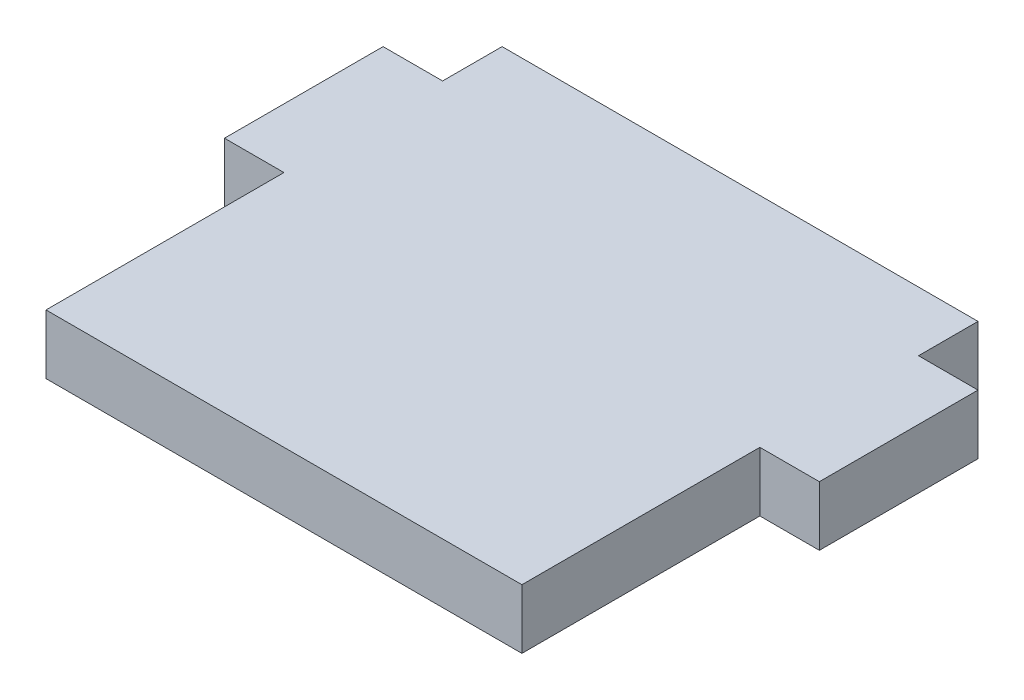
from build123d import *

# Parameters (mm, degrees)
BOSS_EXTRUDE1_DEPTH = 19.05


with BuildPart() as part:
    # Sketch1 → Boss-Extrude1 (new body)
    with BuildSketch(Plane(origin=(0, 0, 0), x_dir=(1, 0, 0), z_dir=(0, 1, 0))):
        Polygon((0, 0), (152.4, 0), (152.4, 76.2), (171.45, 76.2), (171.45, 127), (152.4, 127), (152.4, 146.05), (0, 146.05), (0, 127), (-19.05, 127), (-19.05, 76.2), (0, 76.2), align=None)
    extrude(amount=BOSS_EXTRUDE1_DEPTH)


solid = part.part
